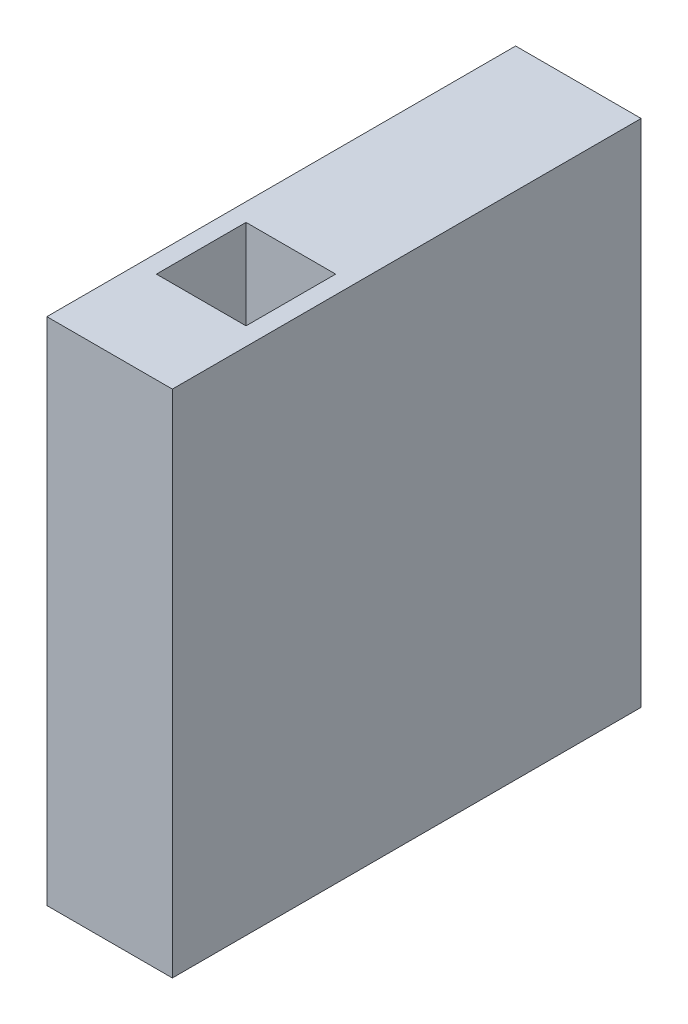
from build123d import *

# Parameters (mm, degrees)
SKETCH_2_W          = 14
SKETCH_2_H          = 52.3
EXTRUDE_1_DEPTH     = 56.9
SKETCH_3_W          = 5
SKETCH_3_H          = 5
CUT_EXTRUDE_1_DEPTH = 56.9


with BuildPart() as part:
    # Эскиз2 → Бобышка-Вытянуть1 (new body)
    with BuildSketch(Plane(origin=(0, 0, 0), x_dir=(1, 0, 0), z_dir=(0, 1, 0))):
        Rectangle(SKETCH_2_W, SKETCH_2_H)
    extrude(amount=EXTRUDE_1_DEPTH)

    # Эскиз3 → Вырез-Вытянуть1 (cut)
    with BuildSketch(Plane(origin=(0, 56.9, 0), x_dir=(1, 0, 0), z_dir=(0, 1, 0))):
        with Locations((-2.5, -13.43)):
            Rectangle(SKETCH_3_W, SKETCH_3_H)
        with Locations((-2.5, -8.43)):
            Rectangle(SKETCH_3_W, SKETCH_3_H)
        with Locations((2.5, -8.43)):
            Rectangle(SKETCH_3_W, SKETCH_3_H)
        with Locations((2.5, -13.43)):
            Rectangle(SKETCH_3_W, SKETCH_3_H)
    extrude(amount=-CUT_EXTRUDE_1_DEPTH, mode=Mode.SUBTRACT)


solid = part.part
